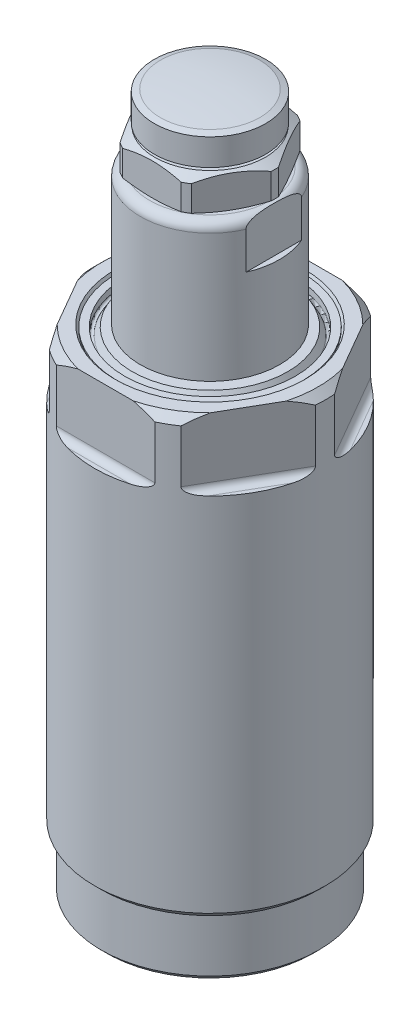
from build123d import *

# Parameters (mm, degrees)
SKETCH2_OUTSIDE_W  = 49.918
SKETCH2_OUTSIDE_H  = 49.918
CUT_EXTRUDE1_DEPTH = 9.144
FILLET1_R          = 0.9144
SKETCH4_W          = 0.79375
SKETCH4_H          = 6.35
CUT_EXTRUDE2_DEPTH = 11.1125
SKETCH5_W          = 4.6736
SKETCH5_H          = 6.35
SKETCH8_OUTSIDE_W  = 54.03
SKETCH8_OUTSIDE_H  = 54.03
CUT_EXTRUDE3_DEPTH = 4.7752


with BuildPart() as part:
    # Sketch1 → Revolve1 (revolve)
    with BuildSketch(Plane.XY):
        with BuildLine():
            Line((9.4615, 0), (10.5918, 0))
            Line((10.5918, 0), (10.9728, 0.381))
            Line((10.9728, 0.381), (14.1097, 0.381))
            Line((14.1097, 0.381), (14.8717, 1.143))
            Line((14.8717, 1.143), (14.8717, 8.3058))
            Line((14.8717, 8.3058), (15.7988, 9.2329))
            Line((15.7988, 9.2329), (15.7988, 66.802))
            Line((15.7988, 66.802), (14.7828, 67.818))
            Line((14.7828, 67.818), (12.993293937, 67.818))
            Line((12.993293937, 67.818), (12.7, 67.31))
            Line((12.7, 67.31), (12.7, 67.5386))
            Line((12.7, 67.5386), (11.684, 67.5386))
            Line((11.684, 67.5386), (11.684, 66.6496))
            ThreePointArc((11.684, 66.6496), (11.495740037, 66.40425484), (11.210029547, 66.5226))
            Line((11.210029547, 66.5226), (10.623441674, 67.5386))
            Line((10.623441674, 67.5386), (0, 67.5386))
            Line((0, 67.5386), (0, 5.1308))
            Line((0, 5.1308), (2.3876, 5.1308))
            Line((2.3876, 5.1308), (2.3876, 1.3208))
            Line((2.3876, 1.3208), (8.5725, 1.3208))
            ThreePointArc((8.5725, 1.3208), (7.943882072, -0.196817928), (9.4615, 0.4318))
            Line((9.4615, 0.4318), (9.4615, 0))
        make_face()
    revolve(axis=Axis((0, 0, 0), (0, 1, 0)))

    # Sketch2 outside → Cut-Extrude1 (cut)
    with BuildSketch(Plane(origin=(0, 67.818, 0), x_dir=(1, 0, 0), z_dir=(0, 1, 0))):
        Rectangle(SKETCH2_OUTSIDE_W, SKETCH2_OUTSIDE_H)
        Polygon((16.497783942, 0), (8.248891971, 14.2875), (-8.248891971, 14.2875), (-16.497783942, 0), (-8.248891971, -14.2875), (8.248891971, -14.2875), align=None, mode=Mode.SUBTRACT)
    extrude(amount=-CUT_EXTRUDE1_DEPTH, mode=Mode.SUBTRACT)

    # Fillet1
    fillet1_edges = [part.edges().sort_by_distance(p)[0] for p in [
        (-12.373337957, 58.674, -7.14375),
        (0, 58.674, -14.2875),
        (12.373337957, 58.674, -7.14375),
        (12.373337957, 58.674, 7.14375),
        (0, 58.674, 14.2875),
        (-12.373337957, 58.674, 7.14375),
    ]]
    fillet(fillet1_edges, radius=FILLET1_R)


with BuildPart() as body_2:
    # Sketch3 → Revolve2 (revolve)
    with BuildSketch(Plane.XY):
        with BuildLine():
            Line((0, 67.818), (0, 86.6394))
            Line((0, 86.6394), (8.255, 86.6394))
            ThreePointArc((8.255, 86.6394), (9.153025612, 86.267425612), (9.525, 85.3694))
            Line((9.525, 85.3694), (9.525, 67.818))
            Line((9.525, 67.818), (0, 67.818))
        make_face()
    revolve(axis=Axis((0, 43.688, 0), (0, 1, 0)))

    # Sketch4 → Cut-Extrude2 (cut, symmetric)
    with BuildSketch(Plane.XY):
        with Locations((-9.128125, 83.4644)):
            Rectangle(SKETCH4_W, SKETCH4_H)
        with Locations((9.128125, 83.4644)):
            Rectangle(SKETCH4_W, SKETCH4_H)
    extrude(amount=CUT_EXTRUDE2_DEPTH, both=True, mode=Mode.SUBTRACT)

    # Sketch5 → 7_16-14 Tapped Hole1 (revolve, cut)
    with BuildSketch(Plane(origin=(0, 86.6394, 0), x_dir=(0, 0, 1), z_dir=(1, 0, 0))):
        with Locations((2.3368, 3.175)):
            Rectangle(SKETCH5_W, SKETCH5_H)
    revolve(axis=Axis((0, 92.9894, 0), (0, -1, 0)), mode=Mode.SUBTRACT)

    # Sketch7 → Revolve3 (revolve)
    with BuildSketch(Plane.XY):
        Polygon((0, 91.4146), (7.570177285, 91.4146), (8.89, 90.6526), (8.89, 87.1474), (7.494281471, 86.6394), (0, 86.6394), align=None)
    revolve(axis=Axis((0, 0, 0), (0, -1, 0)))

    # Sketch8 outside → Cut-Extrude3 (cut)
    with BuildSketch(Plane(origin=(0, 91.4146, 0), x_dir=(1, 0, 0), z_dir=(0, 1, 0))):
        Rectangle(SKETCH8_OUTSIDE_W, SKETCH8_OUTSIDE_H)
        Polygon((9.165435523, 0), (4.582717762, 7.9375), (-4.582717762, 7.9375), (-9.165435523, 0), (-4.582717762, -7.9375), (4.582717762, -7.9375), align=None, mode=Mode.SUBTRACT)
    extrude(amount=-CUT_EXTRUDE3_DEPTH, mode=Mode.SUBTRACT)

    # Sketch9 → Revolve4 (revolve)
    with BuildSketch(Plane.XY):
        with BuildLine():
            Line((0, 96.1898), (0, 91.4146))
            Line((0, 91.4146), (6.960088642, 91.4146))
            Line((6.960088642, 91.4146), (7.62, 91.7956))
            Line((7.62, 91.7956), (7.62, 95.434210996))
            Line((7.62, 95.434210996), (6.80018295, 95.7326))
            ThreePointArc((6.80018295, 95.7326), (3.407767598, 96.075371122), (0, 96.1898))
        make_face()
    revolve(axis=Axis((0, 0, 0), (0, 1, 0)))


solid = Compound([part.part, body_2.part])
